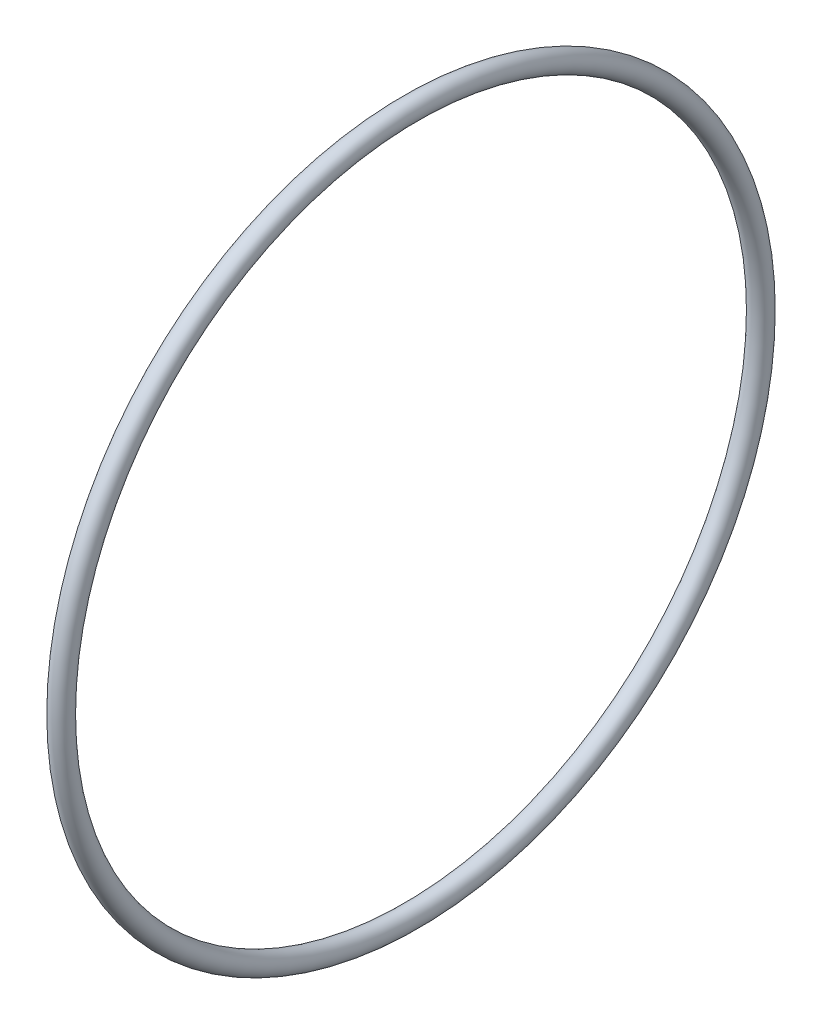
from build123d import *

# Parameters (mm, degrees)
SKETCH3_R = 0.899999978


with BuildPart() as part:
    # Sketch3 → Revolve1 (revolve)
    with BuildSketch(Plane.XY):
        with Locations((-0.915199846, 30.899999922)):
            Circle(SKETCH3_R)
    revolve(axis=Axis((0, 0, 0), (1, 0, 0)))


solid = part.part
